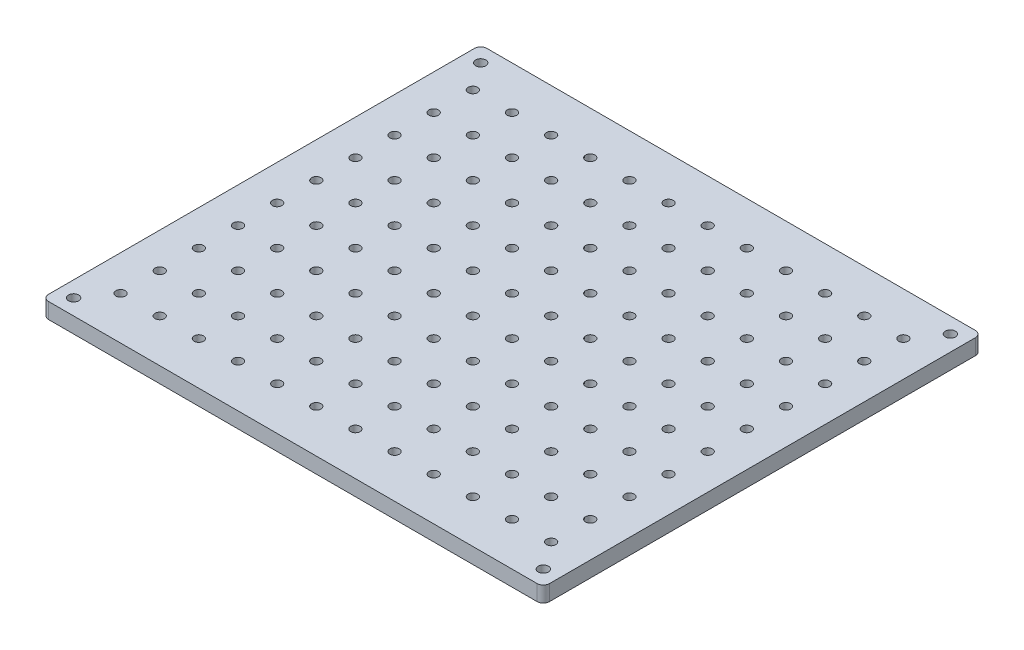
from build123d import *

# Parameters (mm, degrees)
SKETCH_1_W          = 320
SKETCH_1_H          = 280
EXTRUDE_1_DEPTH     = 10
SKETCH_2_R          = 3.25
SKETCH_2_R_2        = 2
CUT_EXTRUDE_1_DEPTH = 5
SKETCH_2_3_R        = 2
CUT_EXTRUDE_2_DEPTH = 213.837966538
SKETCH_4_R          = 3
CUT_EXTRUDE_3_DEPTH = 213.837966538
FILLET_1_R          = 4


with BuildPart() as part:
    # 草图1 → 凸台-拉伸1 (new body)
    with BuildSketch(Plane(origin=(0, 0, 0), x_dir=(1, 0, 0), z_dir=(0, 1, 0))):
        Rectangle(SKETCH_1_W, SKETCH_1_H)
    extrude(amount=EXTRUDE_1_DEPTH)

    # 草图2 → 切除-拉伸1 (cut)
    # profile 1 of 4: a face of its own
    with BuildSketch(Plane(origin=(0, 10, 0), x_dir=(1, 0, 0), z_dir=(0, 1, 0))):
        with Locations((-150, 130)):
            Circle(SKETCH_2_R)
        with Locations((-150, 130)):
            Circle(SKETCH_2_R_2, mode=Mode.SUBTRACT)
    # profile 2 of 4: a face of its own
    with BuildSketch(Plane(origin=(0, 10, 0), x_dir=(1, 0, 0), z_dir=(0, 1, 0))):
        with Locations((150, 130)):
            Circle(SKETCH_2_R)
        with Locations((150, 130)):
            Circle(SKETCH_2_R_2, mode=Mode.SUBTRACT)
    # profile 3 of 4: a face of its own
    with BuildSketch(Plane(origin=(0, 10, 0), x_dir=(1, 0, 0), z_dir=(0, 1, 0))):
        with Locations((-150, -130)):
            Circle(SKETCH_2_R)
        with Locations((-150, -130)):
            Circle(SKETCH_2_R_2, mode=Mode.SUBTRACT)
    # profile 4 of 4: a face of its own
    with BuildSketch(Plane(origin=(0, 10, 0), x_dir=(1, 0, 0), z_dir=(0, 1, 0))):
        with Locations((150, -130)):
            Circle(SKETCH_2_R)
        with Locations((150, -130)):
            Circle(SKETCH_2_R_2, mode=Mode.SUBTRACT)
    extrude(amount=-CUT_EXTRUDE_1_DEPTH, mode=Mode.SUBTRACT)

    # 草图2<3> → 切除-拉伸2 (cut, through all)
    with BuildSketch(Plane(origin=(0, 10, 0), x_dir=(1, 0, 0), z_dir=(0, 1, 0))):
        with Locations((-150, 130)):
            Circle(SKETCH_2_3_R)
        with Locations((150, 130)):
            Circle(SKETCH_2_3_R)
        with Locations((-150, -130)):
            Circle(SKETCH_2_3_R)
        with Locations((150, -130)):
            Circle(SKETCH_2_3_R)
    extrude(amount=-CUT_EXTRUDE_2_DEPTH, mode=Mode.SUBTRACT)

    # 草图4 → 切除-拉伸3 (cut, through all)
    with BuildSketch(Plane(origin=(0, 10, 0), x_dir=(1, 0, 0), z_dir=(0, 1, 0))):
        with Locations((-137.5, 112.5)):
            Circle(SKETCH_4_R)
        with Locations((-112.5, 112.5)):
            Circle(SKETCH_4_R)
        with Locations((-87.5, 112.5)):
            Circle(SKETCH_4_R)
        with Locations((-62.5, 112.5)):
            Circle(SKETCH_4_R)
        with Locations((-37.5, 112.5)):
            Circle(SKETCH_4_R)
        with Locations((-12.5, 112.5)):
            Circle(SKETCH_4_R)
        with Locations((12.5, 112.5)):
            Circle(SKETCH_4_R)
        with Locations((37.5, 112.5)):
            Circle(SKETCH_4_R)
        with Locations((62.5, 112.5)):
            Circle(SKETCH_4_R)
        with Locations((87.5, 112.5)):
            Circle(SKETCH_4_R)
        with Locations((112.5, 112.5)):
            Circle(SKETCH_4_R)
        with Locations((137.5, 112.5)):
            Circle(SKETCH_4_R)
        with Locations((-112.5, 87.5)):
            Circle(SKETCH_4_R)
        with Locations((-87.5, 87.5)):
            Circle(SKETCH_4_R)
        with Locations((-62.5, 87.5)):
            Circle(SKETCH_4_R)
        with Locations((-37.5, 87.5)):
            Circle(SKETCH_4_R)
        with Locations((-12.5, 87.5)):
            Circle(SKETCH_4_R)
        with Locations((12.5, 87.5)):
            Circle(SKETCH_4_R)
        with Locations((37.5, 87.5)):
            Circle(SKETCH_4_R)
        with Locations((62.5, 87.5)):
            Circle(SKETCH_4_R)
        with Locations((87.5, 87.5)):
            Circle(SKETCH_4_R)
        with Locations((112.5, 87.5)):
            Circle(SKETCH_4_R)
        with Locations((137.5, 87.5)):
            Circle(SKETCH_4_R)
        with Locations((-112.5, 62.5)):
            Circle(SKETCH_4_R)
        with Locations((-87.5, 62.5)):
            Circle(SKETCH_4_R)
        with Locations((-62.5, 62.5)):
            Circle(SKETCH_4_R)
        with Locations((-37.5, 62.5)):
            Circle(SKETCH_4_R)
        with Locations((-12.5, 62.5)):
            Circle(SKETCH_4_R)
        with Locations((12.5, 62.5)):
            Circle(SKETCH_4_R)
        with Locations((37.5, 62.5)):
            Circle(SKETCH_4_R)
        with Locations((62.5, 62.5)):
            Circle(SKETCH_4_R)
        with Locations((87.5, 62.5)):
            Circle(SKETCH_4_R)
        with Locations((112.5, 62.5)):
            Circle(SKETCH_4_R)
        with Locations((137.5, 62.5)):
            Circle(SKETCH_4_R)
        with Locations((-112.5, 37.5)):
            Circle(SKETCH_4_R)
        with Locations((-87.5, 37.5)):
            Circle(SKETCH_4_R)
        with Locations((-62.5, 37.5)):
            Circle(SKETCH_4_R)
        with Locations((-37.5, 37.5)):
            Circle(SKETCH_4_R)
        with Locations((-12.5, 37.5)):
            Circle(SKETCH_4_R)
        with Locations((12.5, 37.5)):
            Circle(SKETCH_4_R)
        with Locations((37.5, 37.5)):
            Circle(SKETCH_4_R)
        with Locations((62.5, 37.5)):
            Circle(SKETCH_4_R)
        with Locations((87.5, 37.5)):
            Circle(SKETCH_4_R)
        with Locations((112.5, 37.5)):
            Circle(SKETCH_4_R)
        with Locations((137.5, 37.5)):
            Circle(SKETCH_4_R)
        with Locations((-112.5, 12.5)):
            Circle(SKETCH_4_R)
        with Locations((-87.5, 12.5)):
            Circle(SKETCH_4_R)
        with Locations((-62.5, 12.5)):
            Circle(SKETCH_4_R)
        with Locations((-37.5, 12.5)):
            Circle(SKETCH_4_R)
        with Locations((-12.5, 12.5)):
            Circle(SKETCH_4_R)
        with Locations((12.5, 12.5)):
            Circle(SKETCH_4_R)
        with Locations((37.5, 12.5)):
            Circle(SKETCH_4_R)
        with Locations((62.5, 12.5)):
            Circle(SKETCH_4_R)
        with Locations((87.5, 12.5)):
            Circle(SKETCH_4_R)
        with Locations((112.5, 12.5)):
            Circle(SKETCH_4_R)
        with Locations((137.5, 12.5)):
            Circle(SKETCH_4_R)
        with Locations((-112.5, -12.5)):
            Circle(SKETCH_4_R)
        with Locations((-87.5, -12.5)):
            Circle(SKETCH_4_R)
        with Locations((-62.5, -12.5)):
            Circle(SKETCH_4_R)
        with Locations((-37.5, -12.5)):
            Circle(SKETCH_4_R)
        with Locations((-12.5, -12.5)):
            Circle(SKETCH_4_R)
        with Locations((12.5, -12.5)):
            Circle(SKETCH_4_R)
        with Locations((37.5, -12.5)):
            Circle(SKETCH_4_R)
        with Locations((62.5, -12.5)):
            Circle(SKETCH_4_R)
        with Locations((87.5, -12.5)):
            Circle(SKETCH_4_R)
        with Locations((112.5, -12.5)):
            Circle(SKETCH_4_R)
        with Locations((137.5, -12.5)):
            Circle(SKETCH_4_R)
        with Locations((-112.5, -37.5)):
            Circle(SKETCH_4_R)
        with Locations((-87.5, -37.5)):
            Circle(SKETCH_4_R)
        with Locations((-62.5, -37.5)):
            Circle(SKETCH_4_R)
        with Locations((-37.5, -37.5)):
            Circle(SKETCH_4_R)
        with Locations((-12.5, -37.5)):
            Circle(SKETCH_4_R)
        with Locations((12.5, -37.5)):
            Circle(SKETCH_4_R)
        with Locations((37.5, -37.5)):
            Circle(SKETCH_4_R)
        with Locations((62.5, -37.5)):
            Circle(SKETCH_4_R)
        with Locations((87.5, -37.5)):
            Circle(SKETCH_4_R)
        with Locations((112.5, -37.5)):
            Circle(SKETCH_4_R)
        with Locations((137.5, -37.5)):
            Circle(SKETCH_4_R)
        with Locations((-112.5, -62.5)):
            Circle(SKETCH_4_R)
        with Locations((-87.5, -62.5)):
            Circle(SKETCH_4_R)
        with Locations((-62.5, -62.5)):
            Circle(SKETCH_4_R)
        with Locations((-37.5, -62.5)):
            Circle(SKETCH_4_R)
        with Locations((-12.5, -62.5)):
            Circle(SKETCH_4_R)
        with Locations((12.5, -62.5)):
            Circle(SKETCH_4_R)
        with Locations((37.5, -62.5)):
            Circle(SKETCH_4_R)
        with Locations((62.5, -62.5)):
            Circle(SKETCH_4_R)
        with Locations((87.5, -62.5)):
            Circle(SKETCH_4_R)
        with Locations((112.5, -62.5)):
            Circle(SKETCH_4_R)
        with Locations((137.5, -62.5)):
            Circle(SKETCH_4_R)
        with Locations((-112.5, -87.5)):
            Circle(SKETCH_4_R)
        with Locations((-87.5, -87.5)):
            Circle(SKETCH_4_R)
        with Locations((-62.5, -87.5)):
            Circle(SKETCH_4_R)
        with Locations((-37.5, -87.5)):
            Circle(SKETCH_4_R)
        with Locations((-12.5, -87.5)):
            Circle(SKETCH_4_R)
        with Locations((12.5, -87.5)):
            Circle(SKETCH_4_R)
        with Locations((37.5, -87.5)):
            Circle(SKETCH_4_R)
        with Locations((62.5, -87.5)):
            Circle(SKETCH_4_R)
        with Locations((87.5, -87.5)):
            Circle(SKETCH_4_R)
        with Locations((112.5, -87.5)):
            Circle(SKETCH_4_R)
        with Locations((137.5, -87.5)):
            Circle(SKETCH_4_R)
        with Locations((-112.5, -112.5)):
            Circle(SKETCH_4_R)
        with Locations((-87.5, -112.5)):
            Circle(SKETCH_4_R)
        with Locations((-62.5, -112.5)):
            Circle(SKETCH_4_R)
        with Locations((-37.5, -112.5)):
            Circle(SKETCH_4_R)
        with Locations((-12.5, -112.5)):
            Circle(SKETCH_4_R)
        with Locations((12.5, -112.5)):
            Circle(SKETCH_4_R)
        with Locations((37.5, -112.5)):
            Circle(SKETCH_4_R)
        with Locations((62.5, -112.5)):
            Circle(SKETCH_4_R)
        with Locations((87.5, -112.5)):
            Circle(SKETCH_4_R)
        with Locations((112.5, -112.5)):
            Circle(SKETCH_4_R)
        with Locations((137.5, -112.5)):
            Circle(SKETCH_4_R)
        with Locations((-137.5, 87.5)):
            Circle(SKETCH_4_R)
        with Locations((-137.5, 62.5)):
            Circle(SKETCH_4_R)
        with Locations((-137.5, 37.5)):
            Circle(SKETCH_4_R)
        with Locations((-137.5, 12.5)):
            Circle(SKETCH_4_R)
        with Locations((-137.5, -12.5)):
            Circle(SKETCH_4_R)
        with Locations((-137.5, -37.5)):
            Circle(SKETCH_4_R)
        with Locations((-137.5, -62.5)):
            Circle(SKETCH_4_R)
        with Locations((-137.5, -87.5)):
            Circle(SKETCH_4_R)
        with Locations((-137.5, -112.5)):
            Circle(SKETCH_4_R)
    extrude(amount=-CUT_EXTRUDE_3_DEPTH, mode=Mode.SUBTRACT)

    # 圆角1
    fillet_1_edges = [part.edges().sort_by_distance(p)[0] for p in [
        (-160, 5, 140),
        (160, 5, 140),
        (160, 5, -140),
        (-160, 5, -140),
    ]]
    fillet(fillet_1_edges, radius=FILLET_1_R)


solid = part.part
